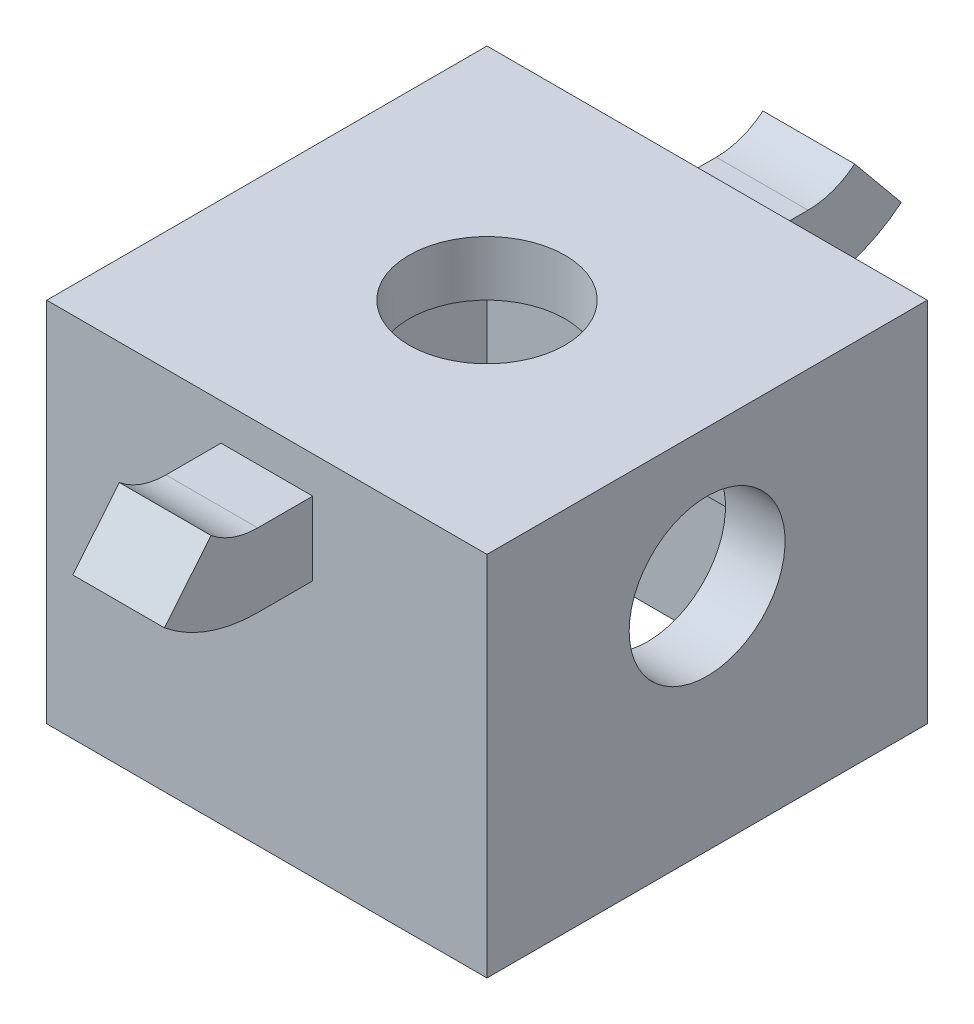
from build123d import *

# Parameters (mm, degrees)
SKETCH1_W           = 24
SKETCH1_H           = 24
BOSS_EXTRUDE1_DEPTH = 20
SKETCH5_W           = 5
SKETCH5_H           = 4
SKETCH3_W           = 20
SKETCH3_H           = 20
CUT_EXTRUDE5_DEPTH  = 6
SKETCH14_W          = 20
SKETCH14_H          = 20
CUT_EXTRUDE6_DEPTH  = 2
SKETCH15_W          = 17.5
SKETCH15_H          = 17.5
CUT_EXTRUDE7_DEPTH  = 9
CUT_EXTRUDE8_REACH  = 5
SKETCH16_R          = 4.25
CUT_EXTRUDE9_REACH  = 5.25
SKETCH17_R          = 4.25


with BuildPart() as part:
    # Sketch1 → Boss-Extrude1 (new body)
    with BuildSketch(Plane(origin=(0, 0, 0), x_dir=(1, 0, 0), z_dir=(0, 1, 0))):
        Rectangle(SKETCH1_W, SKETCH1_H)
    extrude(amount=BOSS_EXTRUDE1_DEPTH)

    # Sweep1: sweep along a path in Sketch6
    with BuildLine(Plane(origin=(0, 0, 0), x_dir=(0, 0, -1), z_dir=(1, 0, 0))) as sweep1_path:
        Line((12, 16), (15, 16))
        ThreePointArc((15, 16), (17.025627927, 16.352272006), (18.813398517, 17.367722833))
    # Sketch5 → Sweep1 (sweep)
    with BuildSketch(Plane(origin=(0, 0, -12), x_dir=(-1, 0, 0), z_dir=(0, 0, -1))):
        with Locations((0, 16)):
            Rectangle(SKETCH5_W, SKETCH5_H)
    sweep1 = sweep(path=sweep1_path.line)

    # Mirror1: Sweep1 across plane
    add(sweep1.mirror(Plane.XY))

    # Sketch3 → Cut-Extrude5 (cut)
    with BuildSketch(Plane.XZ):
        Rectangle(SKETCH3_W, SKETCH3_H)
    extrude(amount=-CUT_EXTRUDE5_DEPTH, mode=Mode.SUBTRACT)

    # Sketch14 → Cut-Extrude6 (cut)
    with BuildSketch(Plane.XZ.offset(-6)):
        Rectangle(SKETCH14_W, SKETCH14_H)
    extrude(amount=-CUT_EXTRUDE6_DEPTH, mode=Mode.SUBTRACT)

    # Sketch15 → Cut-Extrude7 (cut)
    with BuildSketch(Plane.XZ.offset(-8)):
        Rectangle(SKETCH15_W, SKETCH15_H)
    extrude(amount=-CUT_EXTRUDE7_DEPTH, mode=Mode.SUBTRACT)

    # Sketch16 → Cut-Extrude8 (cut, up to next)
    with BuildSketch(Plane.XZ.offset(-17), mode=Mode.PRIVATE) as cut_extrude8_sk1:
        Circle(SKETCH16_R)
    cut_extrude8_tool1 = extrude(cut_extrude8_sk1.sketch, amount=-CUT_EXTRUDE8_REACH, mode=Mode.PRIVATE) & part.part
    add(cut_extrude8_tool1.solids().sort_by_distance((0, 17, 0))[0], mode=Mode.SUBTRACT)

    # Sketch17 → Cut-Extrude9 (cut, up to next)
    with BuildSketch(Plane.ZY.offset(-8.75), mode=Mode.PRIVATE) as cut_extrude9_sk1:
        with Locations((0, 12.5)):
            Circle(SKETCH17_R)
    cut_extrude9_tool1 = extrude(cut_extrude9_sk1.sketch, amount=-CUT_EXTRUDE9_REACH, mode=Mode.PRIVATE) & part.part
    add(cut_extrude9_tool1.solids().sort_by_distance((8.75, 12.5, 0))[0], mode=Mode.SUBTRACT)


solid = part.part
